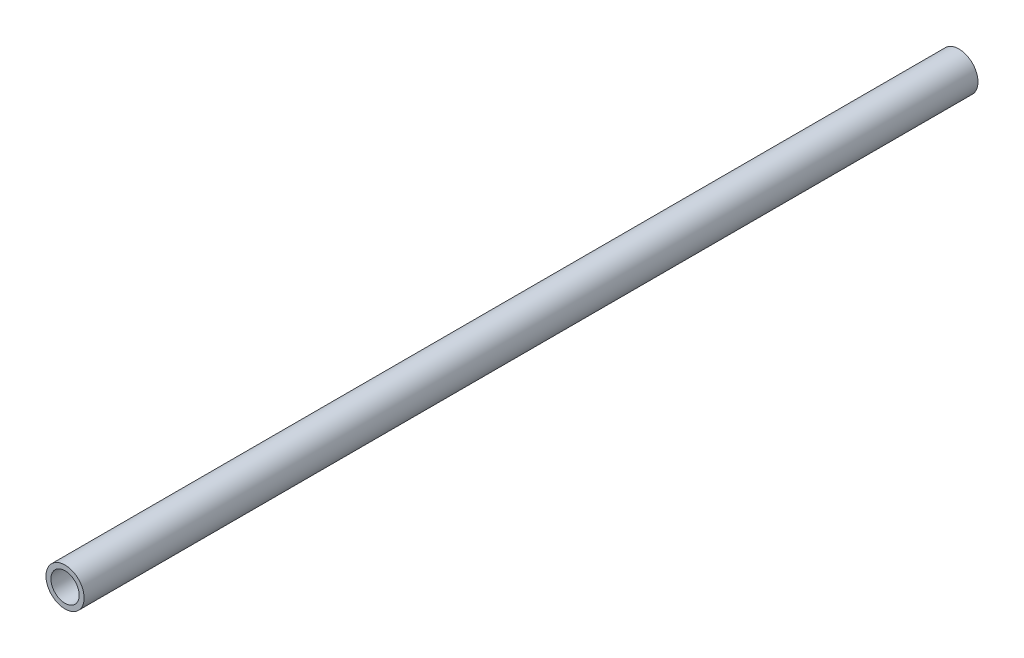
from build123d import *

# Parameters (mm, degrees)
SKETCH1_R           = 10.668
SKETCH1_R_2         = 7.8994
EXTRUDE_THIN1_DEPTH = 250


with BuildPart() as part:
    # Sketch1 → Extrude-Thin1 (new body, symmetric)
    with BuildSketch(Plane.XY):
        Circle(SKETCH1_R)
        Circle(SKETCH1_R_2, mode=Mode.SUBTRACT)
    extrude(amount=EXTRUDE_THIN1_DEPTH, both=True)


solid = part.part
